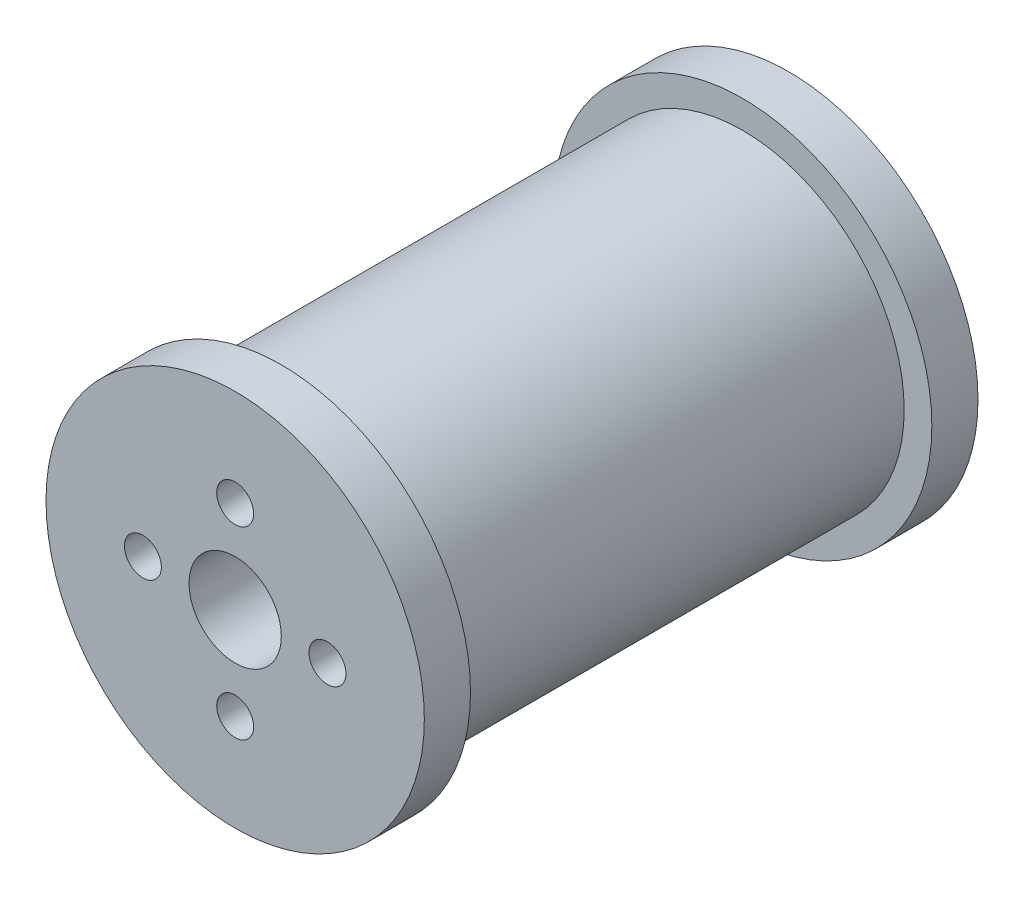
from build123d import *

# Parameters (mm, degrees)
SKETCH1_R           = 17.5
SKETCH1_R_2         = 5
SKETCH1_R_3         = 2
BOSS_EXTRUDE1_DEPTH = 50
SKETCH2_R           = 20.5
SKETCH2_R_2         = 5
SKETCH2_R_3         = 2
BOSS_EXTRUDE2_DEPTH = 5
SKETCH3_R           = 20.5
SKETCH3_R_2         = 5
SKETCH3_R_3         = 2
BOSS_EXTRUDE3_DEPTH = 5


with BuildPart() as part:
    # Sketch1 → Boss-Extrude1 (new body)
    with BuildSketch(Plane.XY):
        Circle(SKETCH1_R)
        Circle(SKETCH1_R_2, mode=Mode.SUBTRACT)
        with Locations((0, 10)):
            Circle(SKETCH1_R_3, mode=Mode.SUBTRACT)
        with Locations((10, 0)):
            Circle(SKETCH1_R_3, mode=Mode.SUBTRACT)
        with Locations((0, -10)):
            Circle(SKETCH1_R_3, mode=Mode.SUBTRACT)
        with Locations((-10, 0)):
            Circle(SKETCH1_R_3, mode=Mode.SUBTRACT)
    extrude(amount=BOSS_EXTRUDE1_DEPTH)

    # Sketch2 → Boss-Extrude2 (add)
    with BuildSketch(Plane.XY.offset(50)):
        Circle(SKETCH2_R)
        Circle(SKETCH2_R_2, mode=Mode.SUBTRACT)
        with Locations((0, 10)):
            Circle(SKETCH2_R_3, mode=Mode.SUBTRACT)
        with Locations((10, 0)):
            Circle(SKETCH2_R_3, mode=Mode.SUBTRACT)
        with Locations((0, -10)):
            Circle(SKETCH2_R_3, mode=Mode.SUBTRACT)
        with Locations((-10, 0)):
            Circle(SKETCH2_R_3, mode=Mode.SUBTRACT)
    extrude(amount=BOSS_EXTRUDE2_DEPTH)

    # Sketch3 → Boss-Extrude3 (add)
    with BuildSketch(Plane(origin=(0, 0, 0), x_dir=(-1, 0, 0), z_dir=(0, 0, -1))):
        Circle(SKETCH3_R)
        Circle(SKETCH3_R_2, mode=Mode.SUBTRACT)
        with Locations((0, 10)):
            Circle(SKETCH3_R_3, mode=Mode.SUBTRACT)
        with Locations((10, 0)):
            Circle(SKETCH3_R_3, mode=Mode.SUBTRACT)
        with Locations((0, -10)):
            Circle(SKETCH3_R_3, mode=Mode.SUBTRACT)
        with Locations((-10, 0)):
            Circle(SKETCH3_R_3, mode=Mode.SUBTRACT)
    extrude(amount=BOSS_EXTRUDE3_DEPTH)


solid = part.part
